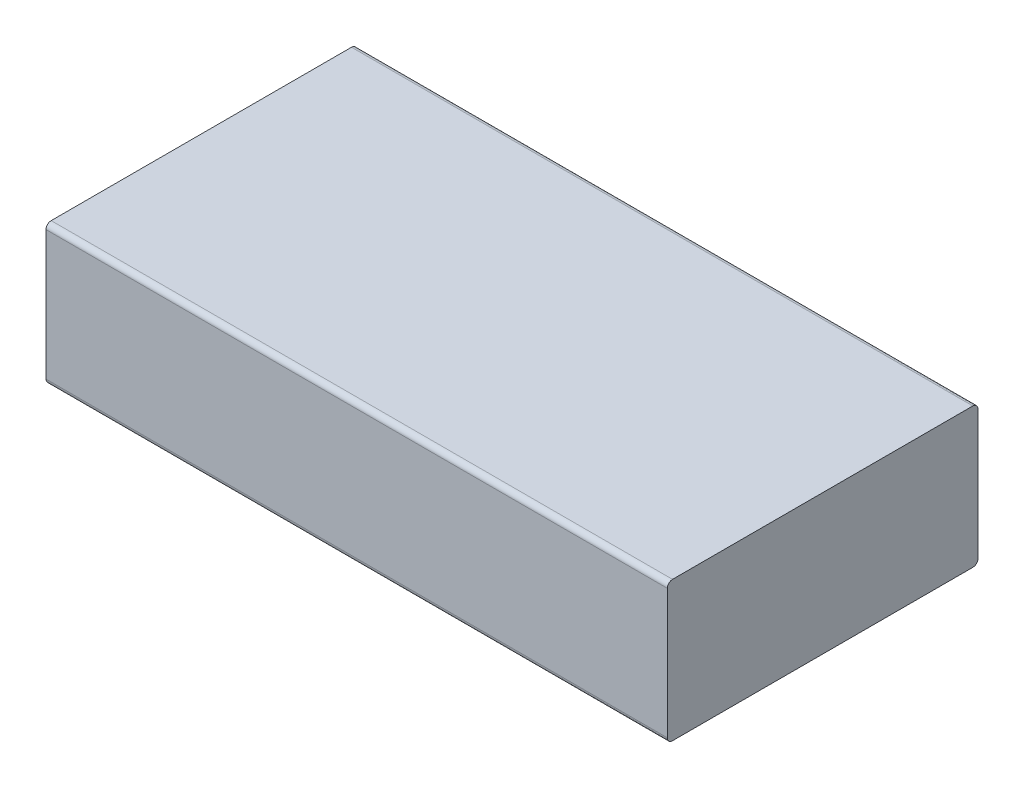
from build123d import *

# Parameters (mm, degrees)
SKETCH2_W           = 60
SKETCH2_H           = 27
BOSS_EXTRUDE1_DEPTH = 60
FILLET1_R           = 1


with BuildPart() as part:
    # Sketch2 → Boss-Extrude1 (new body, symmetric)
    with BuildSketch(Plane(origin=(0, 0, 0), x_dir=(0, 0, -1), z_dir=(1, 0, 0))):
        with Locations((30, 13.5)):
            Rectangle(SKETCH2_W, SKETCH2_H)
    extrude(amount=BOSS_EXTRUDE1_DEPTH, both=True)

    # Fillet1
    fillet1_edges = [part.edges().sort_by_distance(p)[0] for p in [
        (0, 27, 0),
        (0, 27, -60),
        (0, 0, -60),
        (0, 0, 0),
    ]]
    fillet(fillet1_edges, radius=FILLET1_R)


solid = part.part
